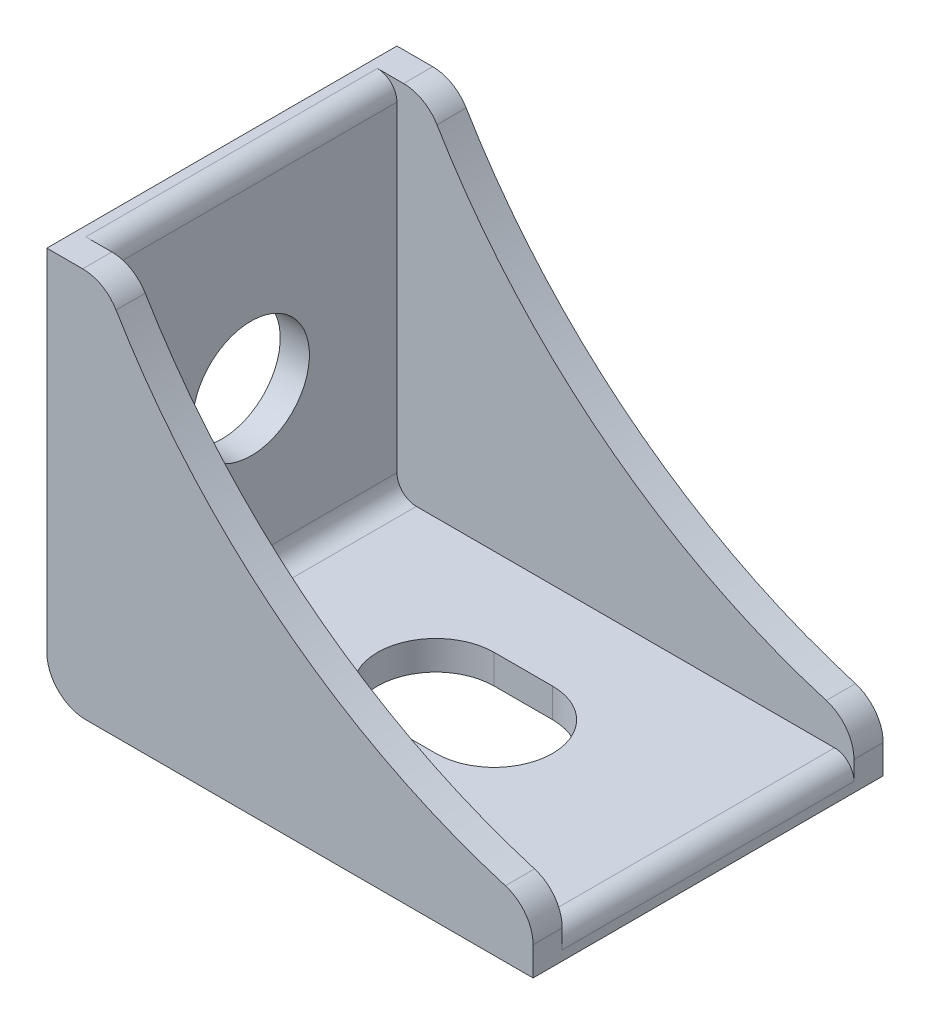
from build123d import *

# Parameters (mm, degrees)
SKETCH_1_W          = 25
SKETCH_1_H          = 18
EXTRUDE_1_DEPTH     = 20
CUT_EXTRUDE_1_DEPTH = 20
SKETCH_3_R          = 3
CUT_EXTRUDE_2_DEPTH = 26
CUT_EXTRUDE_3_DEPTH = 21.0000001
SKETCH_5_W          = 23.5
SKETCH_5_H          = 15
CUT_EXTRUDE_4_DEPTH = 18.5
FILLET_1_R          = 1
FILLET_2_R          = 2


with BuildPart() as part:
    # 스케치1 → 보스-돌출1 (new body)
    with BuildSketch(Plane(origin=(0, 0, 0), x_dir=(1, 0, 0), z_dir=(0, 1, 0))):
        with Locations((12.5, 9)):
            Rectangle(SKETCH_1_W, SKETCH_1_H)
    extrude(amount=EXTRUDE_1_DEPTH)

    # 스케치2 → 컷-돌출1 (cut)
    with BuildSketch(Plane.XY):
        with BuildLine():
            ThreePointArc((3, 20), (12.2395604, 9.221784047), (25, 3))
            Line((25, 3), (25, 20))
            Line((25, 20), (3, 20))
        make_face()
        with BuildLine():
            Line((25, 20), (25, 3))
            ThreePointArc((25, 3), (55.118027728, 9.281565928), (68.640222938, 36.916759096))
            ThreePointArc((68.640222938, 36.916759096), (24.905459141, 70.809293693), (3, 20))
            Line((3, 20), (25, 20))
        make_face()
    extrude(amount=-CUT_EXTRUDE_1_DEPTH, mode=Mode.SUBTRACT)

    # 스케치3 → 컷-돌출2 (cut, through all)
    with BuildSketch(Plane.ZY):
        with Locations((-9, 10)):
            Circle(SKETCH_3_R)
    extrude(amount=-CUT_EXTRUDE_2_DEPTH, mode=Mode.SUBTRACT)

    # 스케치4 → 컷-돌출3 (cut, through all)
    with BuildSketch(Plane.XZ):
        with BuildLine():
            Line((11, -6), (14, -6))
            ThreePointArc((14, -6), (17, -9), (14, -12))
            Line((14, -12), (11, -12))
            ThreePointArc((11, -12), (8, -9), (11, -6))
        make_face()
    extrude(amount=-CUT_EXTRUDE_3_DEPTH, mode=Mode.SUBTRACT)

    # 스케치5 → 컷-돌출4 (cut)
    with BuildSketch(Plane(origin=(0, 20, 0), x_dir=(1, 0, 0), z_dir=(0, 1, 0))):
        with Locations((13.25, 9)):
            Rectangle(SKETCH_5_W, SKETCH_5_H)
    extrude(amount=-CUT_EXTRUDE_4_DEPTH, mode=Mode.SUBTRACT)

    # 필렛1
    fillet_1_edges = [part.edges().sort_by_distance(p)[0] for p in [
        (25, 1.5, -9),
        (1.5, 20, -9),
        (1.5, 1.5, -9),
    ]]
    fillet(fillet_1_edges, radius=FILLET_1_R)

    # 필렛2
    fillet_2_edges = [part.edges().sort_by_distance(p)[0] for p in [
        (3, 20, -0.75),
        (25, 3, -17.25),
        (0, 0, -9),
        (3, 20, -17.25),
        (25, 3, -0.75),
    ]]
    fillet(fillet_2_edges, radius=FILLET_2_R)


solid = part.part
